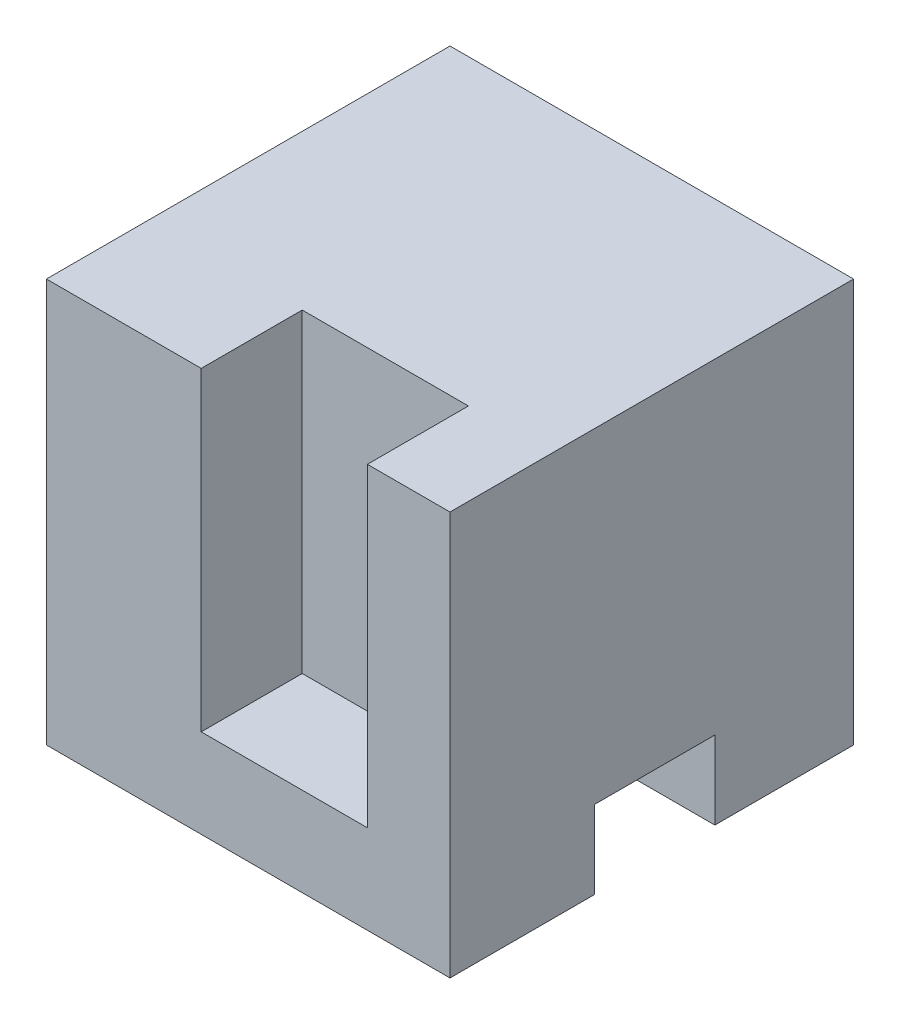
from build123d import *

# Parameters (mm, degrees)
SKICA2_W                 = 50
SKICA2_H                 = 50
P_IDAT_VYSUNUT_M1_DEPTH  = 25
SKICA3_W                 = 20.588514008
SKICA3_H                 = 12.517673613
ODEBRAT_VYSUNUT_M1_DEPTH = 39
SKICA4_W                 = 14.884932554
SKICA4_H                 = 9.667623342
ODEBRAT_VYSUNUT_M2_DEPTH = 39
SKICA5_W                 = 16.426867347
SKICA5_H                 = 18.535662784
ODEBRAT_VYSUNUT_M3_DEPTH = 39


with BuildPart() as part:
    # Skica2 → Přidat vysunutím1 (new body, symmetric)
    with BuildSketch(Plane.XY):
        with Locations((25, 25)):
            Rectangle(SKICA2_W, SKICA2_H)
    extrude(amount=P_IDAT_VYSUNUT_M1_DEPTH, both=True)

    # Skica3 → Odebrat vysunutím1 (cut)
    with BuildSketch(Plane(origin=(0, 50, 0), x_dir=(1, 0, 0), z_dir=(0, 1, 0))):
        with Locations((29.470091853, -18.741163194)):
            Rectangle(SKICA3_W, SKICA3_H)
    extrude(amount=-ODEBRAT_VYSUNUT_M1_DEPTH, mode=Mode.SUBTRACT)

    # Skica4 → Odebrat vysunutím2 (cut)
    with BuildSketch(Plane(origin=(50, 0, 0), x_dir=(0, 0, -1), z_dir=(1, 0, 0))):
        with Locations((0.371136043, 4.833811671)):
            Rectangle(SKICA4_W, SKICA4_H)
    extrude(amount=-ODEBRAT_VYSUNUT_M2_DEPTH, mode=Mode.SUBTRACT)

    # Skica5 → Odebrat vysunutím3 (cut)
    with BuildSketch(Plane.ZY):
        with Locations((-16.786566327, 34.267831392)):
            Rectangle(SKICA5_W, SKICA5_H)
    extrude(amount=-ODEBRAT_VYSUNUT_M3_DEPTH, mode=Mode.SUBTRACT)


solid = part.part
